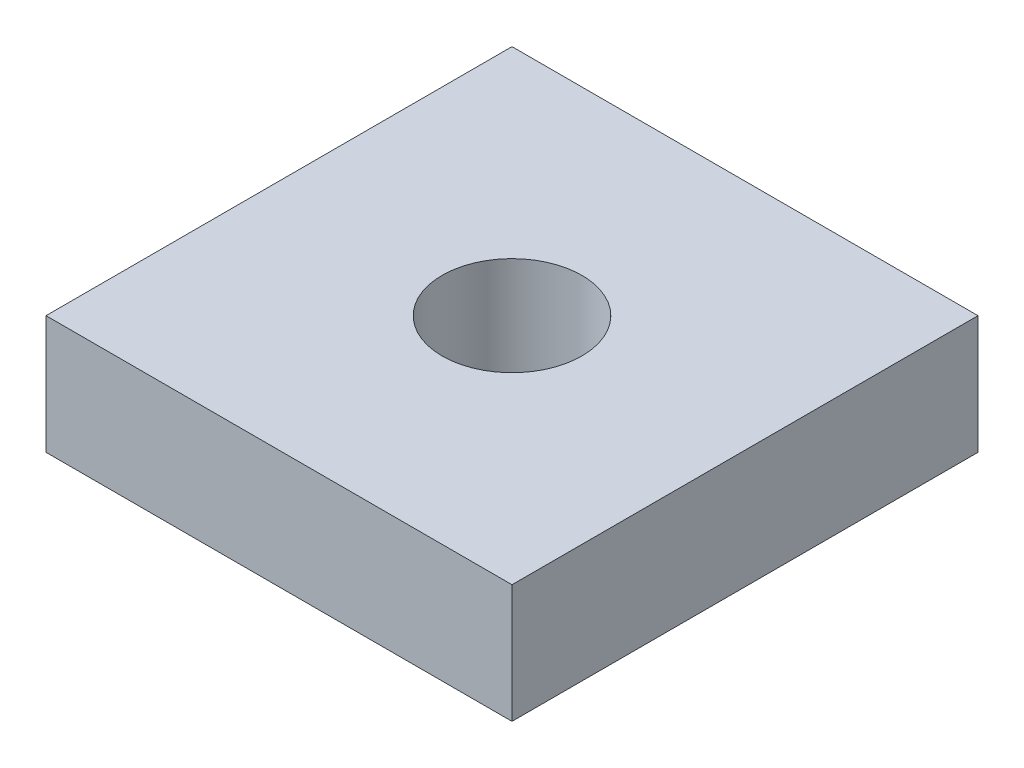
from build123d import *

# Parameters (mm, degrees)
SKETCH1_W           = 10
SKETCH1_H           = 10
SKETCH1_R           = 1.5
BOSS_EXTRUDE1_DEPTH = 2.54


with BuildPart() as part:
    # Sketch1 → Boss-Extrude1 (new body)
    with BuildSketch(Plane(origin=(0, 0, 0), x_dir=(1, 0, 0), z_dir=(0, 1, 0))):
        with Locations((0.948553055, -1.446945338)):
            Rectangle(SKETCH1_W, SKETCH1_H)
        with Locations((0.948553055, -1.446945338)):
            Circle(SKETCH1_R, mode=Mode.SUBTRACT)
    extrude(amount=BOSS_EXTRUDE1_DEPTH)


solid = part.part
